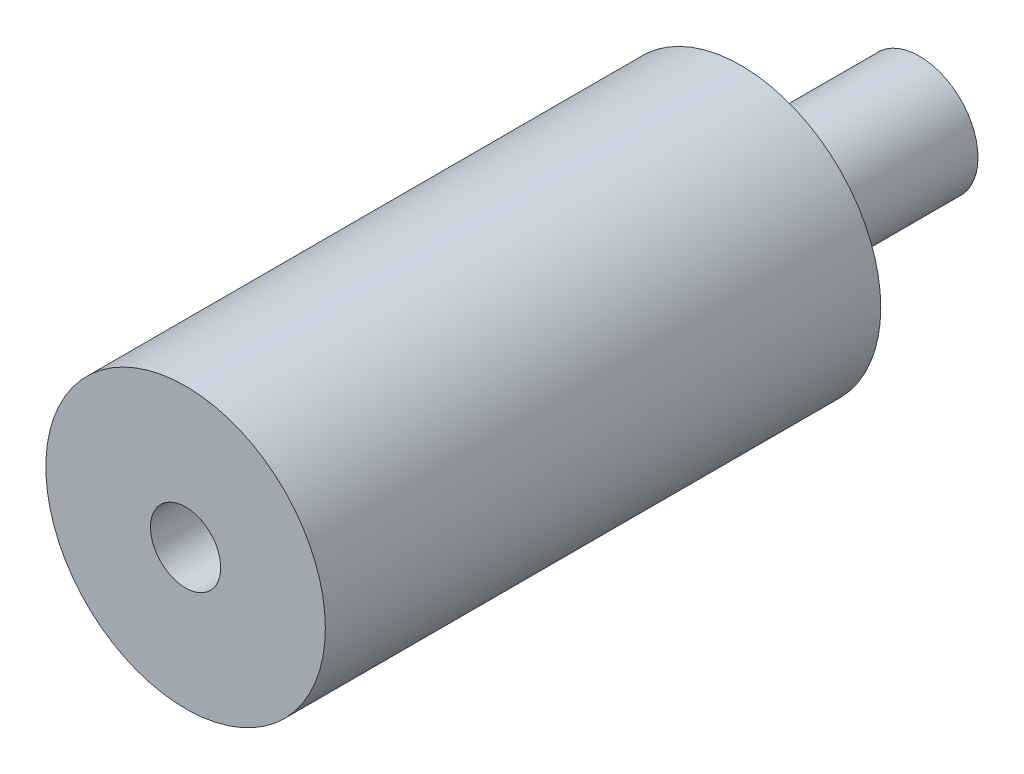
from build123d import *

# Parameters (mm, degrees)
SKETCH1_R      = 5.969
SKETCH1_R_2    = 1.5
EXTRUDE1_DEPTH = 23.7236
SKETCH2_R      = 2.5019
SKETCH2_R_2    = 1.5
EXTRUDE2_DEPTH = 7.62


with BuildPart() as part:
    # Sketch1 → Extrude1 (new body)
    with BuildSketch(Plane.XY):
        Circle(SKETCH1_R)
        Circle(SKETCH1_R_2, mode=Mode.SUBTRACT)
    extrude(amount=EXTRUDE1_DEPTH)

    # Sketch2 → Extrude2 (add)
    with BuildSketch(Plane(origin=(0, 0, 0), x_dir=(-1, 0, 0), z_dir=(0, 0, -1))):
        Circle(SKETCH2_R)
        Circle(SKETCH2_R_2, mode=Mode.SUBTRACT)
    extrude(amount=EXTRUDE2_DEPTH)


solid = part.part
